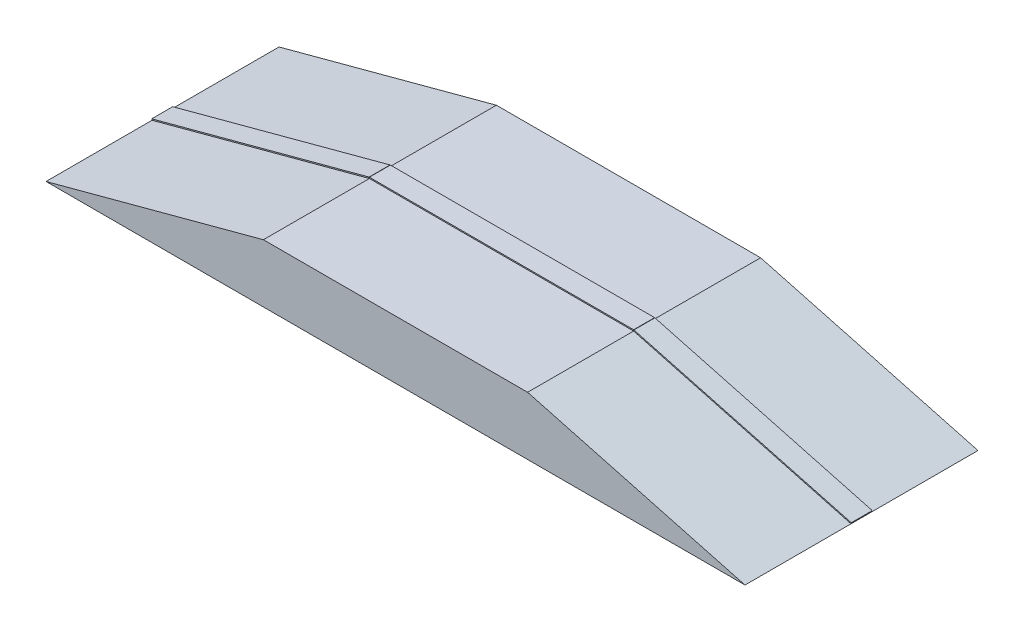
from build123d import *

# Parameters (mm, degrees)
EXTRUDE_1_DEPTH = 100
SKETCH_3_W      = 193.185165257
SKETCH_3_H      = 18
EXTRUDE_2_DEPTH = 1
SKETCH_4_W      = 226.794919244
SKETCH_4_H      = 18
EXTRUDE_3_DEPTH = 1
SKETCH_5_W      = 193.185165258
SKETCH_5_H      = 18
EXTRUDE_4_DEPTH = 1


with BuildPart() as part:
    # 草圖1 → 填料-伸長1 (new body, symmetric)
    with BuildSketch(Plane.XY):
        Polygon((0, 0), (600, 0), (413.397459622, 50), (186.602540378, 50), align=None)
    extrude(amount=EXTRUDE_1_DEPTH, both=True)


with BuildPart() as body_2:
    # 草圖3 → 填料-伸長2 (new body)
    with BuildSketch(Plane(origin=(40.192378865, 150, 0), x_dir=(0.965925826, -0.258819045, 0), z_dir=(0.258819045, 0.965925826, 0))):
        with Locations((482.962913145, 0)):
            Rectangle(SKETCH_3_W, SKETCH_3_H)
    extrude(amount=EXTRUDE_2_DEPTH)


with BuildPart() as body_3:
    # 草圖4 → 填料-伸長3 (new body)
    with BuildSketch(Plane(origin=(0, 50, 0), x_dir=(1, 0, 0), z_dir=(0, 1, 0))):
        with Locations((300, 0)):
            Rectangle(SKETCH_4_W, SKETCH_4_H)
    extrude(amount=EXTRUDE_3_DEPTH)


with BuildPart() as body_4:
    # 草圖5 → 填料-伸長4 (new body)
    with BuildSketch(Plane(origin=(0, 0, 0), x_dir=(0.965925826, 0.258819045, 0), z_dir=(-0.258819045, 0.965925826, 0))):
        with Locations((96.592582629, 0)):
            Rectangle(SKETCH_5_W, SKETCH_5_H)
    extrude(amount=EXTRUDE_4_DEPTH)


solid = Compound([part.part, body_2.part, body_3.part, body_4.part])
